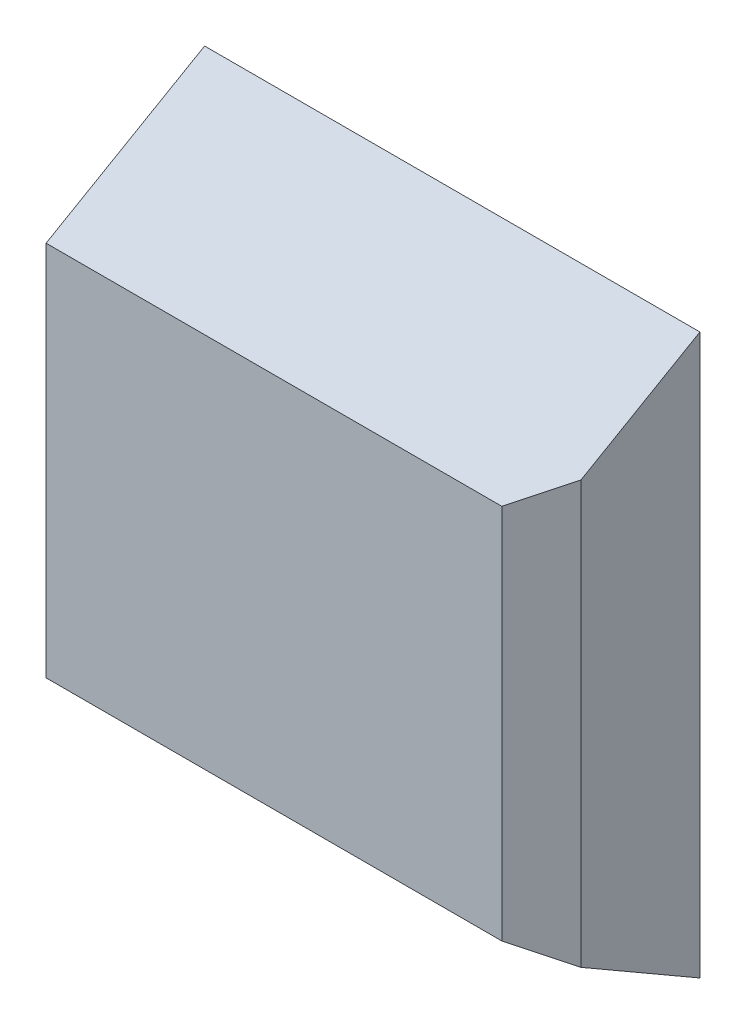
from build123d import *

# Parameters (mm, degrees)
SKETCH1_W           = 12.5
SKETCH1_H           = 14.118802154
BOSS_EXTRUDE1_DEPTH = 4
DRAFT1_ANGLE        = -30
CHAMFER1_SIZE       = 1


with BuildPart() as part:
    # Sketch1 → Boss-Extrude1 (new body)
    with BuildSketch(Plane.XY.offset(4)):
        with Locations((6.25, 7.059401077)):
            Rectangle(SKETCH1_W, SKETCH1_H)
    extrude(amount=-BOSS_EXTRUDE1_DEPTH)

    # Draft1
    draft1_faces = [part.faces().sort_by_distance(p)[0] for p in [
        (6.25, 14.118802154, 2),
        (6.25, 0, 2),
    ]]
    draft(draft1_faces, Plane(origin=(0, 0, 0), x_dir=(-1, 0, 0), z_dir=(0, 0, -1)), DRAFT1_ANGLE)

    # Chamfer1
    chamfer1_edges = [part.edges().sort_by_distance(p)[0] for p in [
        (12.5, 7.059401077, 4),
    ]]
    chamfer(chamfer1_edges, length=CHAMFER1_SIZE)


solid = part.part
